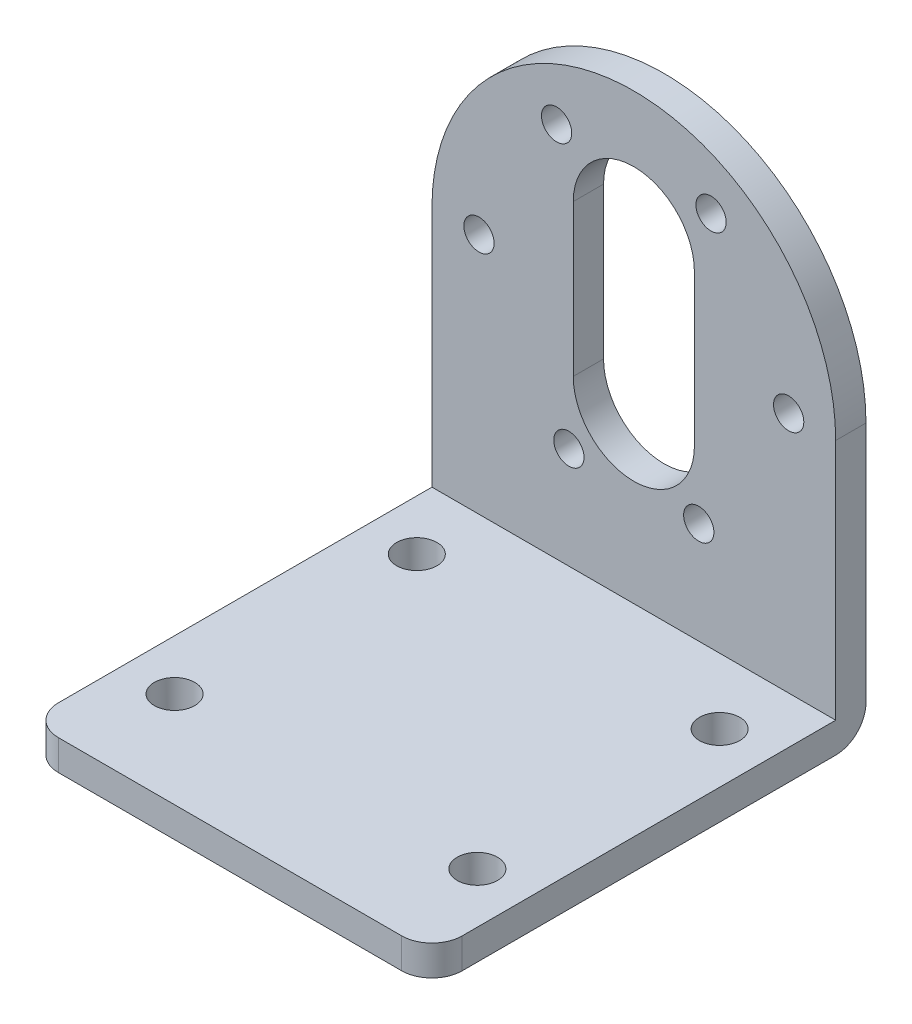
from build123d import *

# Parameters (mm, degrees)
SKETCH3_W               = 40
SKETCH3_H               = 43
BOSS_EXTRUDE1_DEPTH     = 3
SKETCH4_W               = 40
SKETCH4_H               = 3
BOSS_EXTRUDE2_DEPTH     = 24
SKETCH6_R               = 20
BOSS_EXTRUDE3_DEPTH     = 3
SKETCH7_R               = 1.5
CUT_EXTRUDE1_DEPTH      = 8
FILLET1_R               = 3
SKETCH8_R               = 2
CUT_EXTRUDE2_DEPTH      = 8
MIRROR3_COPY_1_SKETCH_R = 2
MIRROR3_COPY_1_DEPTH    = 8
FILLET2_R               = 3
CUT_EXTRUDE3_DEPTH      = 8


with BuildPart() as part:
    # Sketch3 → Boss-Extrude1 (new body)
    with BuildSketch(Plane(origin=(0, 0, 0), x_dir=(1, 0, 0), z_dir=(0, 1, 0))):
        Rectangle(SKETCH3_W, SKETCH3_H)
    extrude(amount=BOSS_EXTRUDE1_DEPTH)

    # Sketch4 → Boss-Extrude2 (add)
    with BuildSketch(Plane(origin=(0, 3, 0), x_dir=(1, 0, 0), z_dir=(0, 1, 0))):
        with Locations((0, 20)):
            Rectangle(SKETCH4_W, SKETCH4_H)
    extrude(amount=BOSS_EXTRUDE2_DEPTH)

    # Sketch6 → Boss-Extrude3 (add)
    with BuildSketch(Plane.XY.offset(-18.5)):
        with Locations((0, 27)):
            Circle(SKETCH6_R)
    extrude(amount=-BOSS_EXTRUDE3_DEPTH)

    # Sketch7 → Cut-Extrude1 (cut)
    with BuildSketch(Plane.XY.offset(-18.5)):
        with Locations((7.65, 40.296356644)):
            Circle(SKETCH7_R)
        with Locations((15.34, 27)):
            Circle(SKETCH7_R)
        with Locations((6.432903226, 13.074004305)):
            Circle(SKETCH7_R)
    cut_extrude1 = extrude(amount=-CUT_EXTRUDE1_DEPTH, mode=Mode.SUBTRACT)

    # Mirror1: Cut-Extrude1 across plane
    add(cut_extrude1.mirror(Plane(origin=(0, 0, 0), x_dir=(0, 0, 1), z_dir=(1, 0, 0))), mode=Mode.SUBTRACT)

    # Fillet1
    fillet1_edges = [part.edges().sort_by_distance(p)[0] for p in [
        (0, 0, -21.5),
    ]]
    fillet(fillet1_edges, radius=FILLET1_R)

    # Sketch8 → Cut-Extrude2 (cut)
    with BuildSketch(Plane(origin=(0, 3, 0), x_dir=(1, 0, 0), z_dir=(0, 1, 0))):
        with Locations((-15, 12)):
            Circle(SKETCH8_R)
    cut_extrude2 = extrude(amount=-CUT_EXTRUDE2_DEPTH, mode=Mode.SUBTRACT)

    # Mirror2: Cut-Extrude2 across plane
    add(cut_extrude2.mirror(Plane(origin=(0, 0, 0), x_dir=(0, 0, 1), z_dir=(1, 0, 0))), mode=Mode.SUBTRACT)

    # Mirror3: Cut-Extrude2 across plane
    add(cut_extrude2.mirror(Plane.XY), mode=Mode.SUBTRACT)

    # Mirror3 copy 1 sketch → Mirror3 copy 1 (cut)
    with BuildSketch(Plane(origin=(0, 3, 0), x_dir=(-1, 0, 0), z_dir=(0, 1, 0))):
        with Locations((-15, 12)):
            Circle(MIRROR3_COPY_1_SKETCH_R)
    extrude(amount=-MIRROR3_COPY_1_DEPTH, mode=Mode.SUBTRACT)

    # Fillet2
    fillet2_edges = [part.edges().sort_by_distance(p)[0] for p in [
        (20, 1.5, 21.5),
        (-20, 1.5, 21.5),
    ]]
    fillet(fillet2_edges, radius=FILLET2_R)

    # Sketch9 → Cut-Extrude3 (cut)
    with BuildSketch(Plane.XY.offset(-18.5)):
        with BuildLine():
            Line((6, 34.5), (6, 19.5))
            ThreePointArc((6, 19.5), (0, 13.5), (-6, 19.5))
            Line((-6, 19.5), (-6, 34.5))
            ThreePointArc((-6, 34.5), (0, 40.5), (6, 34.5))
        make_face()
    extrude(amount=-CUT_EXTRUDE3_DEPTH, mode=Mode.SUBTRACT)


solid = part.part
